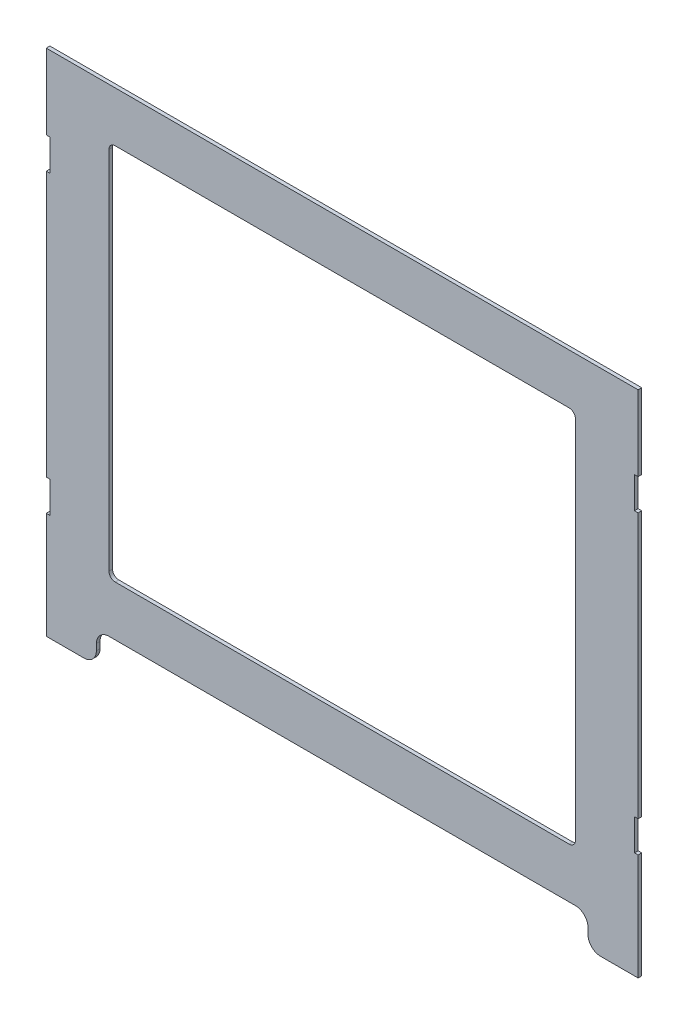
from build123d import *

# Parameters (mm, degrees)
BOSS_EXTRUDE1_DEPTH = 2.9
CUT_EXTRUDE1_DEPTH  = 3.9


with BuildPart() as part:
    # Sketch1 → Boss-Extrude1 (new body)
    with BuildSketch(Plane.XY):
        with BuildLine():
            Line((206.1, -203.2), (236.1, -203.2))
            Line((236.1, -203.2), (236.1, -118.2))
            Line((236.1, -118.2), (233.2, -118.2))
            Line((233.2, -118.2), (233.2, -93.2))
            Line((233.2, -93.2), (236.1, -93.2))
            Line((236.1, -93.2), (236.1, 118.2))
            Line((236.1, 118.2), (233.2, 118.2))
            Line((233.2, 118.2), (233.2, 143.2))
            Line((233.2, 143.2), (236.1, 143.2))
            Line((236.1, 143.2), (236.1, 203.2))
            Line((236.1, 203.2), (-236.1, 203.2))
            Line((-236.1, 203.2), (-236.1, 143.2))
            Line((-236.1, 143.2), (-233.2, 143.2))
            Line((-233.2, 143.2), (-233.2, 118.2))
            Line((-233.2, 118.2), (-236.1, 118.2))
            Line((-236.1, 118.2), (-236.1, -93.2))
            Line((-236.1, -93.2), (-233.2, -93.2))
            Line((-233.2, -93.2), (-233.2, -118.2))
            Line((-233.2, -118.2), (-236.1, -118.2))
            Line((-236.1, -118.2), (-236.1, -203.2))
            Line((-236.1, -203.2), (-206.1, -203.2))
            ThreePointArc((-206.1, -203.2), (-199.028932188, -200.271067812), (-196.1, -193.2))
            Line((-196.1, -193.2), (-196.1, -188.2))
            ThreePointArc((-196.1, -188.2), (-193.171067812, -181.128932188), (-186.1, -178.2))
            Line((-186.1, -178.2), (186.1, -178.2))
            ThreePointArc((186.1, -178.2), (193.171067812, -181.128932188), (196.1, -188.2))
            Line((196.1, -188.2), (196.1, -193.2))
            ThreePointArc((196.1, -193.2), (199.028932188, -200.271067812), (206.1, -203.2))
        make_face()
    extrude(amount=BOSS_EXTRUDE1_DEPTH)

    # Sketch2 → Cut-Extrude1 (cut, through all)
    with BuildSketch(Plane.XY.offset(2.9)):
        with BuildLine():
            Line((-181.1, 163.2), (181.1, 163.2))
            ThreePointArc((181.1, 163.2), (184.635533906, 161.735533906), (186.1, 158.2))
            Line((186.1, 158.2), (186.1, -133.2))
            ThreePointArc((186.1, -133.2), (184.635533906, -136.735533906), (181.1, -138.2))
            Line((181.1, -138.2), (-181.1, -138.2))
            ThreePointArc((-181.1, -138.2), (-184.635533906, -136.735533906), (-186.1, -133.2))
            Line((-186.1, -133.2), (-186.1, 158.2))
            ThreePointArc((-186.1, 158.2), (-184.635533906, 161.735533906), (-181.1, 163.2))
        make_face()
    extrude(amount=-CUT_EXTRUDE1_DEPTH, mode=Mode.SUBTRACT)


solid = part.part
